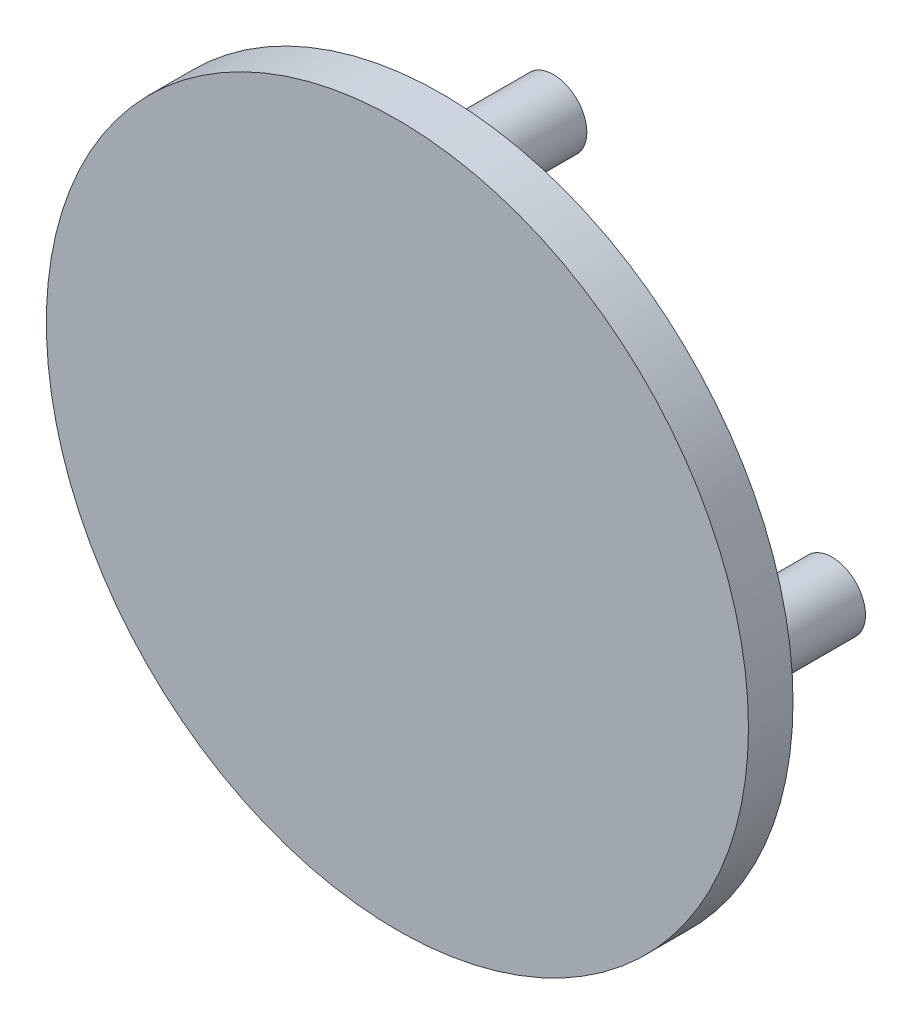
from build123d import *

# Parameters (mm, degrees)
SKETCH1_R           = 25
BOSS_EXTRUDE1_DEPTH = 8
SKETCH2_R           = 63
BOSS_EXTRUDE2_DEPTH = 8
SKETCH4_R           = 6
BOSS_EXTRUDE3_DEPTH = 20


with BuildPart() as part:
    # Sketch1 → Boss-Extrude1 (new body)
    with BuildSketch(Plane.XY):
        Circle(SKETCH1_R)
    extrude(amount=BOSS_EXTRUDE1_DEPTH)

    # Sketch2 → Boss-Extrude2 (add)
    with BuildSketch(Plane.XY.offset(8)):
        Circle(SKETCH2_R)
    extrude(amount=BOSS_EXTRUDE2_DEPTH)

    # Sketch4 → Boss-Extrude3 (add)
    with BuildSketch(Plane(origin=(0, 0, 8), x_dir=(-1, 0, 0), z_dir=(0, 0, -1))):
        with Locations((0, 50)):
            Circle(SKETCH4_R)
        with Locations((50, 0)):
            Circle(SKETCH4_R)
        with Locations((0, -50)):
            Circle(SKETCH4_R)
        with Locations((-50, 0)):
            Circle(SKETCH4_R)
    extrude(amount=BOSS_EXTRUDE3_DEPTH)


solid = part.part
